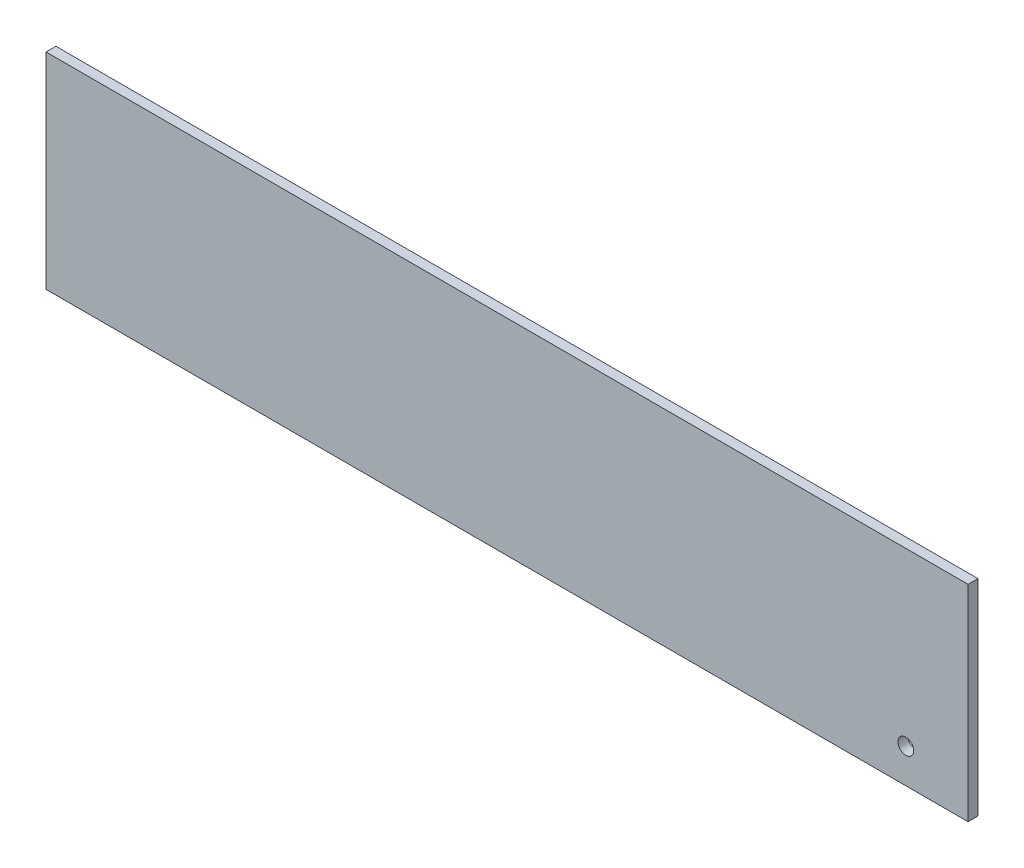
from build123d import *

# Parameters (mm, degrees)
SKETCH1_W           = 592
SKETCH1_H           = 132
SKETCH1_R           = 5.05
BOSS_EXTRUDE1_DEPTH = 6.35


with BuildPart() as part:
    # Sketch1 → Boss-Extrude1 (new body)
    with BuildSketch(Plane.XY):
        with Locations((296, 66)):
            Rectangle(SKETCH1_W, SKETCH1_H)
        with Locations((552, 22)):
            Circle(SKETCH1_R, mode=Mode.SUBTRACT)
    extrude(amount=BOSS_EXTRUDE1_DEPTH)


solid = part.part
